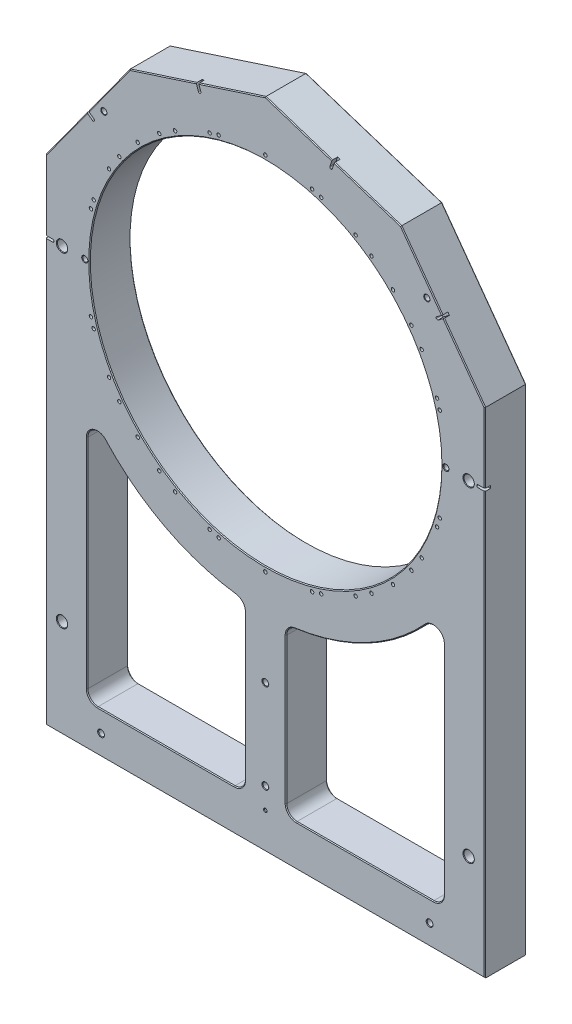
from build123d import *

# Parameters (mm, degrees)
SKETCH1_W                                     = 540
SKETCH1_H                                     = 820
SKETCH1_R                                     = 216.2
EXTRUDE1_DEPTH                                = 25.4
F_1_2_0_5_DIAMETER_HOLE1_AT_2_COUNT           = 2
F_1_2_0_5_DIAMETER_HOLE1_AT_2_PITCH           = 500
F_1_2_0_5_DIAMETER_HOLE1_AT_3_COUNT           = 2
F_1_2_0_5_DIAMETER_HOLE1_AT_3_PITCH           = 640.312424
F_1_2_0_5_DIAMETER_HOLE1_AT_4_COUNT           = 2
F_1_2_0_5_DIAMETER_HOLE1_AT_4_PITCH           = 400
SKETCH426_R                                   = 8.5
CUT_EXTRUDE1_DEPTH                            = 2
CHAMFER4_SIZE                                 = 0.5
TAPPED_HOLE_FOR_1_4_28_HELICOIL2_D            = 6.6294
TAPPED_HOLE_FOR_1_4_28_HELICOIL2_DEPTH        = 28.22
TAPPED_HOLE_FOR_1_4_28_HELICOIL2_CSINK_D      = 8.8773
TAPPED_HOLE_FOR_1_4_28_HELICOIL2_CSINK_ANGLE  = 90
TAPPED_HOLE_FOR_1_4_28_HELICOIL2_TIP          = 1.991673
CBORE_FOR_1_4_SOCKET_HEAD_CAP_SCREW2_AT_COUNT = 2
CBORE_FOR_1_4_SOCKET_HEAD_CAP_SCREW2_AT_PITCH = 110
CBORE_FOR_1_4_SOCKET_HEAD_CAP_SCREW3_AT_COUNT = 2
CBORE_FOR_1_4_SOCKET_HEAD_CAP_SCREW3_AT_PITCH = 404
EXTRUDE4_DEPTH                                = 51.8
F_1_8_0_125_DIAMETER_HOLE1_D                  = 3.175
F_1_8_0_125_DIAMETER_HOLE1_DEPTH              = 12.7
F_1_8_0_125_DIAMETER_HOLE1_CSINK_D            = 4.445
F_1_8_0_125_DIAMETER_HOLE1_CSINK_ANGLE        = 90
F_1_8_0_125_DIAMETER_HOLE1_TIP                = 0.953866
EXTRUDE5_DEPTH                                = 7
FILLET1_R                                     = 1.5875
CIRPATTERN1_COUNT                             = 10
FILLET1_OF_CIRPATTERN1_R                      = 1.5875
EXTRUDE11_DEPTH                               = 51.8
FILLET3_R                                     = 12.7
CHAMFER2_SIZE                                 = 1
FILLET3_OF_MIRROR6_R                          = 12.7
CHAMFER2_OF_MIRROR6_SIZE                      = 1
CHAMFER1_SIZE                                 = 1
CHAMFER3_SIZE                                 = 1
CIRPATTERN2_COUNT                             = 20
CIRPATTERN4_COUNT                             = 24


with BuildPart() as part:
    # Sketch1 → Extrude1 (new body, symmetric)
    with BuildSketch(Plane.XY):
        with Locations((0, -110)):
            Rectangle(SKETCH1_W, SKETCH1_H)
        Circle(SKETCH1_R, mode=Mode.SUBTRACT)
    extrude(amount=EXTRUDE1_DEPTH, both=True)

    # Sketch424 → 1_2 _0.5_ Diameter Hole1 (revolve, cut)
    with BuildSketch(Plane(origin=(250, -400, -25.4), x_dir=(0, 1, 0), z_dir=(1, 0, 0))):
        Polygon((0, 0), (0, 50.8), (6.985, 50.8), (6.35, 50.165), (6.35, 0.635), (6.985, 0), align=None)
    f_1_2_0_5_diameter_hole1 = revolve(axis=Axis((250, -400, -31.75), (0, 0, 1)), mode=Mode.SUBTRACT)

    # 1_2 _0.5_ Diameter Hole1 at 2: 1_2 _0.5_ Diameter Hole1 ×2
    with Locations(*[(-i * F_1_2_0_5_DIAMETER_HOLE1_AT_2_PITCH, 0, 0) for i in range(1, F_1_2_0_5_DIAMETER_HOLE1_AT_2_COUNT)]):
        add(f_1_2_0_5_diameter_hole1, mode=Mode.SUBTRACT)

    # 1_2 _0.5_ Diameter Hole1 at 3: 1_2 _0.5_ Diameter Hole1 ×2
    with Locations(*[Vector(-0.780869, 0.624695, 0) * (i * F_1_2_0_5_DIAMETER_HOLE1_AT_3_PITCH) for i in range(1, F_1_2_0_5_DIAMETER_HOLE1_AT_3_COUNT)]):
        add(f_1_2_0_5_diameter_hole1, mode=Mode.SUBTRACT)

    # 1_2 _0.5_ Diameter Hole1 at 4: 1_2 _0.5_ Diameter Hole1 ×2
    with Locations(*[(0, i * F_1_2_0_5_DIAMETER_HOLE1_AT_4_PITCH, 0) for i in range(1, F_1_2_0_5_DIAMETER_HOLE1_AT_4_COUNT)]):
        add(f_1_2_0_5_diameter_hole1, mode=Mode.SUBTRACT)

    # Sketch426 → Cut-Extrude1 (cut)
    with BuildSketch(Plane(origin=(0, 0, -25.4), x_dir=(-1, 0, 0), z_dir=(0, 0, -1))):
        with Locations((-250, 0)):
            Circle(SKETCH426_R)
        with Locations((250, 0)):
            Circle(SKETCH426_R)
    extrude(amount=-CUT_EXTRUDE1_DEPTH, mode=Mode.SUBTRACT)

    # Chamfer4
    chamfer4_edges = [part.edges().sort_by_distance(p)[0] for p in [
        (258.5, 0, -25.4),
        (250, -6.35, -23.4),
        (-241.5, 0, -25.4),
        (-250, -6.35, -23.4),
    ]]
    chamfer(chamfer4_edges, length=CHAMFER4_SIZE)

    # Tapped Hole for 1_4-28 Helicoil2
    with Locations(Plane(origin=(235, 0, -25.4), x_dir=(-1, 0, 0), z_dir=(0, 0, -1))):
        with Locations((0, 0), (470, 0)):
            CounterSinkHole(TAPPED_HOLE_FOR_1_4_28_HELICOIL2_D / 2, TAPPED_HOLE_FOR_1_4_28_HELICOIL2_CSINK_D / 2, depth=TAPPED_HOLE_FOR_1_4_28_HELICOIL2_DEPTH, counter_sink_angle=TAPPED_HOLE_FOR_1_4_28_HELICOIL2_CSINK_ANGLE)
            with Locations((0, 0, -(TAPPED_HOLE_FOR_1_4_28_HELICOIL2_DEPTH + TAPPED_HOLE_FOR_1_4_28_HELICOIL2_TIP / 2))):  # 118° drill point
                Cone(0, TAPPED_HOLE_FOR_1_4_28_HELICOIL2_D / 2, TAPPED_HOLE_FOR_1_4_28_HELICOIL2_TIP, mode=Mode.SUBTRACT)

    # Sketch14 → CBORE for 1_4 Socket Head Cap Screw2 (revolve, cut)
    with BuildSketch(Plane(origin=(0, -340, -25.4), x_dir=(0, 1, 0), z_dir=(1, 0, 0))):
        Polygon((0, 0), (0, 50.8), (4.20624, 50.8), (3.57124, 50.165), (3.57124, 6.35), (5.55625, 6.35), (5.55625, 0), align=None)
    cbore_for_1_4_socket_head_cap_screw2 = revolve(axis=Axis((0, -340, -31.75), (0, 0, 1)), mode=Mode.SUBTRACT)

    # CBORE for 1_4 Socket Head Cap Screw2 at: CBORE for 1_4 Socket Head Cap Screw2 ×2
    with Locations(*[(0, -i * CBORE_FOR_1_4_SOCKET_HEAD_CAP_SCREW2_AT_PITCH, 0) for i in range(1, CBORE_FOR_1_4_SOCKET_HEAD_CAP_SCREW2_AT_COUNT)]):
        add(cbore_for_1_4_socket_head_cap_screw2, mode=Mode.SUBTRACT)

    # Sketch16 → CBORE for 1_4 Socket Head Cap Screw3 (revolve, cut)
    with BuildSketch(Plane(origin=(202, -495, -25.4), x_dir=(0, 1, 0), z_dir=(1, 0, 0))):
        Polygon((0, 0), (0, 50.8), (4.20624, 50.8), (3.57124, 50.165), (3.57124, 6.35), (5.55625, 6.35), (5.55625, 0), align=None)
    cbore_for_1_4_socket_head_cap_screw3 = revolve(axis=Axis((202, -495, -31.75), (0, 0, 1)), mode=Mode.SUBTRACT)

    # CBORE for 1_4 Socket Head Cap Screw3 at: CBORE for 1_4 Socket Head Cap Screw3 ×2
    with Locations(*[(-i * CBORE_FOR_1_4_SOCKET_HEAD_CAP_SCREW3_AT_PITCH, 0, 0) for i in range(1, CBORE_FOR_1_4_SOCKET_HEAD_CAP_SCREW3_AT_COUNT)]):
        add(cbore_for_1_4_socket_head_cap_screw3, mode=Mode.SUBTRACT)

    # Sketch31 → Extrude4 (cut, through all)
    with BuildSketch(Plane(origin=(0, 0, -25.4), x_dir=(-1, 0, 0), z_dir=(0, 0, -1))):
        Polygon((0, 283.894801), (-166.869177, 229.675718), (-270, 87.728318), (-270, 363.672388), (270, 363.672388), (270, 87.728318), (166.869177, 229.675718), align=None)
    extrude(amount=-EXTRUDE4_DEPTH, mode=Mode.SUBTRACT)

    # 1_8 _0.125_ Diameter Hole1
    with Locations(Plane.XY.offset(25.4)):
        with Locations((0, -476)):
            CounterSinkHole(F_1_8_0_125_DIAMETER_HOLE1_D / 2, F_1_8_0_125_DIAMETER_HOLE1_CSINK_D / 2, depth=F_1_8_0_125_DIAMETER_HOLE1_DEPTH, counter_sink_angle=F_1_8_0_125_DIAMETER_HOLE1_CSINK_ANGLE)
            with Locations((0, 0, -(F_1_8_0_125_DIAMETER_HOLE1_DEPTH + F_1_8_0_125_DIAMETER_HOLE1_TIP / 2))):  # 118° drill point
                Cone(0, F_1_8_0_125_DIAMETER_HOLE1_D / 2, F_1_8_0_125_DIAMETER_HOLE1_TIP, mode=Mode.SUBTRACT)

    # Sketch32 → Extrude5 (cut)
    with BuildSketch(Plane(origin=(0, 0, 25.4), x_dir=(-1, 0, 0), z_dir=(0, 0, -1))):
        Polygon((-84.95043, 256.292733), (-81.918747, 257.277786), (-78.828577, 247.767221), (-81.86026, 246.782168), align=None)
    extrude5 = extrude(amount=EXTRUDE5_DEPTH, mode=Mode.SUBTRACT)

    # Fillet1
    fillet1_edges = [part.edges().sort_by_distance(p)[0] for p in [
        (81.86026, 246.782168, 21.9),
        (78.828577, 247.767221, 21.9),
    ]]
    fillet(fillet1_edges, radius=FILLET1_R)

    # CirPattern1: Extrude5 ×10 about axis, 4 skipped
    cirpattern1_axis = Axis((0, 0, 0), (0, 0, -1))
    add([extrude5.rotate(cirpattern1_axis, i * 360 / CIRPATTERN1_COUNT) for i in range(1, CIRPATTERN1_COUNT) if i not in (3, 4, 5, 6)], mode=Mode.SUBTRACT)

    # Fillet1 of CirPattern1
    fillet1_of_cirpattern1_edges = [part.edges().sort_by_distance(p)[0] for p in [
        (211.28126, 151.534714, 21.9),
        (209.407577, 154.113617, 21.9),
        (260, -1.59385, 21.9),
        (260, 1.59385, 21.9),
        (-260, 1.59385, 21.9),
        (-260, -1.59385, 21.9),
        (-209.407577, 154.113617, 21.9),
        (-211.28126, 151.534714, 21.9),
        (-78.828577, 247.767221, 21.9),
        (-81.86026, 246.782168, 21.9),
    ]]
    fillet(fillet1_of_cirpattern1_edges, radius=FILLET1_OF_CIRPATTERN1_R)

    # Sketch35 → Tapped Hole for 1_4-28 Helicoil6 (revolve, cut)
    with BuildSketch(Plane(origin=(-198.588713, 169.004505, 25.4), x_dir=(0, -1, 0), z_dir=(1, 0, 0))):
        Polygon((0, 0), (0, 30.211673), (3.3147, 28.22), (3.3147, 0.4953), (3.81, 0), align=None)
    tapped_hole_for_1_4_28_helicoil6 = revolve(axis=Axis((-198.588713, 169.004505, 31.75), (0, 0, -1)), mode=Mode.SUBTRACT)

    # Mirror4: Tapped Hole for 1_4-28 Helicoil6 across plane
    add(tapped_hole_for_1_4_28_helicoil6.mirror(Plane(origin=(0, 0, 0), x_dir=(0, 0, 1), z_dir=(1, 0, 0))), mode=Mode.SUBTRACT)

    # Sketch44 → Extrude11 (cut, through all)
    with BuildSketch(Plane(origin=(0, 0, -25.4), x_dir=(-1, 0, 0), z_dir=(0, 0, -1))):
        with BuildLine():
            Line((-219.2, -152.447893), (-219.2, -469.2))
            Line((-219.2, -469.2), (-25.4, -469.2))
            Line((-25.4, -469.2), (-25.4, -265.789089))
            ThreePointArc((-25.4, -265.789089), (-134.791864, -230.478097), (-219.2, -152.447893))
        make_face()
    extrude11 = extrude(amount=-EXTRUDE11_DEPTH, mode=Mode.SUBTRACT)

    # Fillet3
    fillet3_edges = [part.edges().sort_by_distance(p)[0] for p in [
        (219.2, -152.447893, 0),
        (25.4, -265.789089, 0),
        (25.4, -469.2, 0),
        (219.2, -469.2, 0),
    ]]
    fillet(fillet3_edges, radius=FILLET3_R)

    # Chamfer2
    chamfer2_edges = [part.edges().sort_by_distance(p)[0] for p in [
        (25.4, -366.796454, -25.4),
        (25.4, -366.796454, 25.4),
        (122.3, -469.2, -25.4),
        (122.3, -469.2, 25.4),
        (219.2, -322.576348, -25.4),
        (219.2, -322.576348, 25.4),
        (124.143895, -236.383784, -25.4),
        (124.143895, -236.383784, 25.4),
        (29.119744, -465.480256, -25.4),
        (29.119744, -465.480256, 25.4),
        (215.480256, -465.480256, -25.4),
        (215.480256, -465.480256, 25.4),
        (28.527631, -268.746667, -25.4),
        (28.527631, -268.746667, 25.4),
        (211.094074, -176.812744, -25.4),
        (211.094074, -176.812744, 25.4),
    ]]
    chamfer(chamfer2_edges, length=CHAMFER2_SIZE)

    # Mirror6: Extrude11 across plane
    add(extrude11.mirror(Plane(origin=(0, 0, 0), x_dir=(0, 0, 1), z_dir=(1, 0, 0))), mode=Mode.SUBTRACT)

    # Fillet3 of Mirror6
    fillet3_of_mirror6_edges = [part.edges().sort_by_distance(p)[0] for p in [
        (-219.2, -152.447893, 0),
        (-25.4, -265.789089, 0),
        (-25.4, -469.2, 0),
        (-219.2, -469.2, 0),
    ]]
    fillet(fillet3_of_mirror6_edges, radius=FILLET3_OF_MIRROR6_R)

    # Chamfer2 of Mirror6
    chamfer2_of_mirror6_edges = [part.edges().sort_by_distance(p)[0] for p in [
        (-25.4, -366.796454, -25.4),
        (-25.4, -366.796454, 25.4),
        (-122.3, -469.2, -25.4),
        (-122.3, -469.2, 25.4),
        (-219.2, -322.576348, -25.4),
        (-219.2, -322.576348, 25.4),
        (-124.143895, -236.383784, -25.4),
        (-124.143895, -236.383784, 25.4),
        (-29.119744, -465.480256, -25.4),
        (-29.119744, -465.480256, 25.4),
        (-215.480256, -465.480256, -25.4),
        (-215.480256, -465.480256, 25.4),
        (-28.527631, -268.746667, -25.4),
        (-28.527631, -268.746667, 25.4),
        (-211.094074, -176.812744, -25.4),
        (-211.094074, -176.812744, 25.4),
    ]]
    chamfer(chamfer2_of_mirror6_edges, length=CHAMFER2_OF_MIRROR6_SIZE)

    # Chamfer1
    chamfer1_edges = [part.edges().sort_by_distance(p)[0] for p in [
        (270, -260.796925, 25.4),
        (-270, -216.135841, -25.4),
        (-270, 44.661084, 25.4),
        (218.434588, 158.702018, -25.4),
        (83.434588, 256.785259, -25.4),
        (-83.434588, 256.785259, -25.4),
        (-218.434588, 158.702018, -25.4),
        (-40.959374, 270.586293, 25.4),
        (125.909803, 242.984225, 25.4),
        (244.685715, 122.570442, 25.4),
        (-192.183462, 194.833594, 25.4),
        (40.959374, 270.586293, 25.4),
        (192.183462, 194.833594, 25.4),
        (270, 44.661084, 25.4),
        (-270, -260.796925, 25.4),
        (-244.685715, 122.570442, 25.4),
        (-125.909803, 242.984225, 25.4),
        (270, -216.135841, -25.4),
        (0, -520, -25.4),
        (0, -520, 25.4),
    ]]
    chamfer(chamfer1_edges, length=CHAMFER1_SIZE)

    # Chamfer3
    chamfer3_edges = [part.edges().sort_by_distance(p)[0] for p in [
        (-216.2, 0, -25.4),
        (-216.2, 0, 25.4),
    ]]
    chamfer(chamfer3_edges, length=CHAMFER3_SIZE)

    # Sketch422 → 4.2 _4.2_ Diameter Hole1 (revolve, cut)
    with BuildSketch(Plane(origin=(-222, 0, 25.4), x_dir=(0, -1, 0), z_dir=(1, 0, 0))):
        Polygon((0, 0), (0, 50.8), (2.125, 50.8), (2.1, 50.775), (2.1, 0.025), (2.125, 0), align=None)
    f_4_2_4_2_diameter_hole1 = revolve(axis=Axis((-222, 0, 31.75), (0, 0, -1)), mode=Mode.SUBTRACT)

    # CirPattern2: 4.2 _4.2_ Diameter Hole1 ×20 about axis
    cirpattern2_axis = Axis((0, 0, 0), (0, 0, 1))
    for i in range(1, CIRPATTERN2_COUNT):
        add(f_4_2_4_2_diameter_hole1.rotate(cirpattern2_axis, i * 360 / CIRPATTERN2_COUNT), mode=Mode.SUBTRACT)

    # Sketch414 → 1_4 _0.25_ Diameter Hole2 (revolve, cut)
    with BuildSketch(Plane(origin=(-222, 0, 25.4), x_dir=(0, -1, 0), z_dir=(1, 0, 0))):
        Polygon((0, 0), (0, 50.8), (3.81, 50.8), (3.175, 50.165), (3.175, 0.635), (3.81, 0), align=None)
    f_1_4_0_25_diameter_hole2 = revolve(axis=Axis((-222, 0, 31.75), (0, 0, -1)), mode=Mode.SUBTRACT)

    # Mirror7: 1_4 _0.25_ Diameter Hole2 across plane
    add(f_1_4_0_25_diameter_hole2.mirror(Plane(origin=(0, 0, 0), x_dir=(0, 0, 1), z_dir=(1, 0, 0))), mode=Mode.SUBTRACT)

    # CirPattern4: 4.2 _4.2_ Diameter Hole1 ×24 about axis, 1 skipped
    cirpattern4_axis = Axis((0, 0, 25.4), (0, 0, -1))
    add([f_4_2_4_2_diameter_hole1.rotate(cirpattern4_axis, i * 360 / CIRPATTERN4_COUNT) for i in range(1, CIRPATTERN4_COUNT) if i not in (12,)], mode=Mode.SUBTRACT)


solid = part.part
